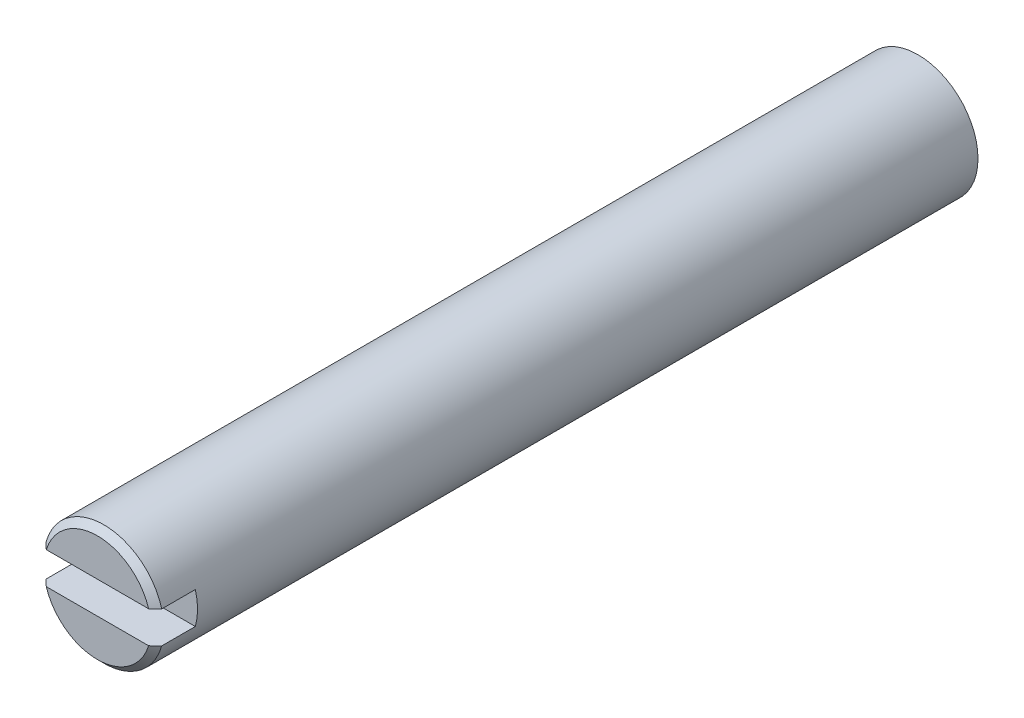
from build123d import *

# Parameters (mm, degrees)
SKETCH1_R           = 4.7625
BOSS_EXTRUDE1_DEPTH = 65.1002
CHAMFER1_SIZE       = 0.508
SKETCH2_W           = 12.7
SKETCH2_H           = 2.54
CUT_EXTRUDE1_DEPTH  = 3.175


with BuildPart() as part:
    # Sketch1 → Boss-Extrude1 (new body)
    with BuildSketch(Plane.XY):
        Circle(SKETCH1_R)
    extrude(amount=BOSS_EXTRUDE1_DEPTH)

    # Chamfer1
    chamfer1_edges = [part.edges().sort_by_distance(p)[0] for p in [
        (-4.7625, 0, 65.1002),
    ]]
    chamfer(chamfer1_edges, length=CHAMFER1_SIZE)

    # Sketch2 → Cut-Extrude1 (cut)
    with BuildSketch(Plane.XY.offset(65.1002)):
        Rectangle(SKETCH2_W, SKETCH2_H)
    extrude(amount=-CUT_EXTRUDE1_DEPTH, mode=Mode.SUBTRACT)


solid = part.part
